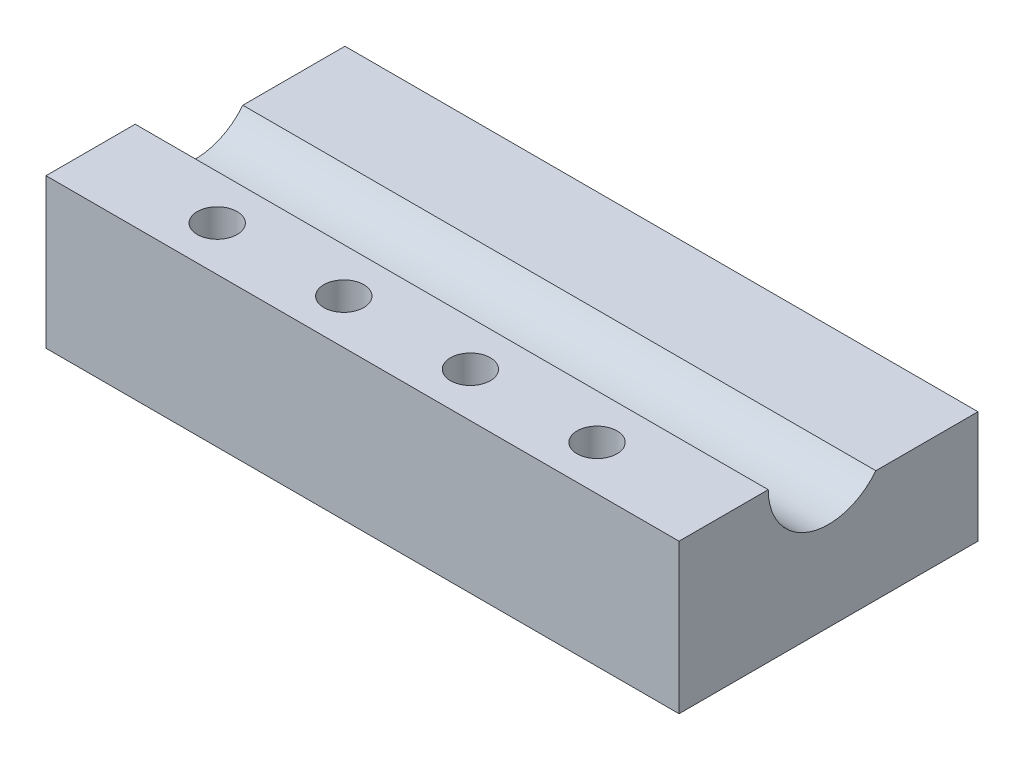
from build123d import *

# Parameters (mm, degrees)
SKETCH1_W           = 25.41
SKETCH1_H           = 12
BOSS_EXTRUDE1_DEPTH = 6
SKETCH2_R           = 2.42
CUT_EXTRUDE1_DEPTH  = 25.41
SKETCH3_W           = 4.543452961
SKETCH3_H           = 1.5
CUT_EXTRUDE2_DEPTH  = 25.41
SKETCH4_R           = 0.8
CUT_EXTRUDE4_DEPTH  = 7


with BuildPart() as part:
    # Sketch1 → Boss-Extrude1 (new body)
    with BuildSketch(Plane(origin=(0, 0, 0), x_dir=(1, 0, 0), z_dir=(0, 1, 0))):
        with Locations((12.705, 6)):
            Rectangle(SKETCH1_W, SKETCH1_H)
    extrude(amount=BOSS_EXTRUDE1_DEPTH)

    # Sketch2 → Cut-Extrude1 (cut)
    with BuildSketch(Plane.ZY):
        with Locations((-6, 6)):
            Circle(SKETCH2_R)
    extrude(amount=-CUT_EXTRUDE1_DEPTH, mode=Mode.SUBTRACT)

    # Sketch3 → Cut-Extrude2 (cut)
    with BuildSketch(Plane.ZY):
        with Locations((-9.72827352, 5.25)):
            Rectangle(SKETCH3_W, SKETCH3_H)
    extrude(amount=-CUT_EXTRUDE2_DEPTH, mode=Mode.SUBTRACT)

    # Sketch4 → Cut-Extrude4 (cut, through all)
    with BuildSketch(Plane(origin=(0, 6, 0), x_dir=(1, 0, 0), z_dir=(0, 1, 0))):
        with Locations((5.082, 1.79)):
            Circle(SKETCH4_R)
        with Locations((10.164, 1.79)):
            Circle(SKETCH4_R)
        with Locations((15.246, 1.79)):
            Circle(SKETCH4_R)
        with Locations((20.328, 1.79)):
            Circle(SKETCH4_R)
    extrude(amount=-CUT_EXTRUDE4_DEPTH, mode=Mode.SUBTRACT)


solid = part.part
